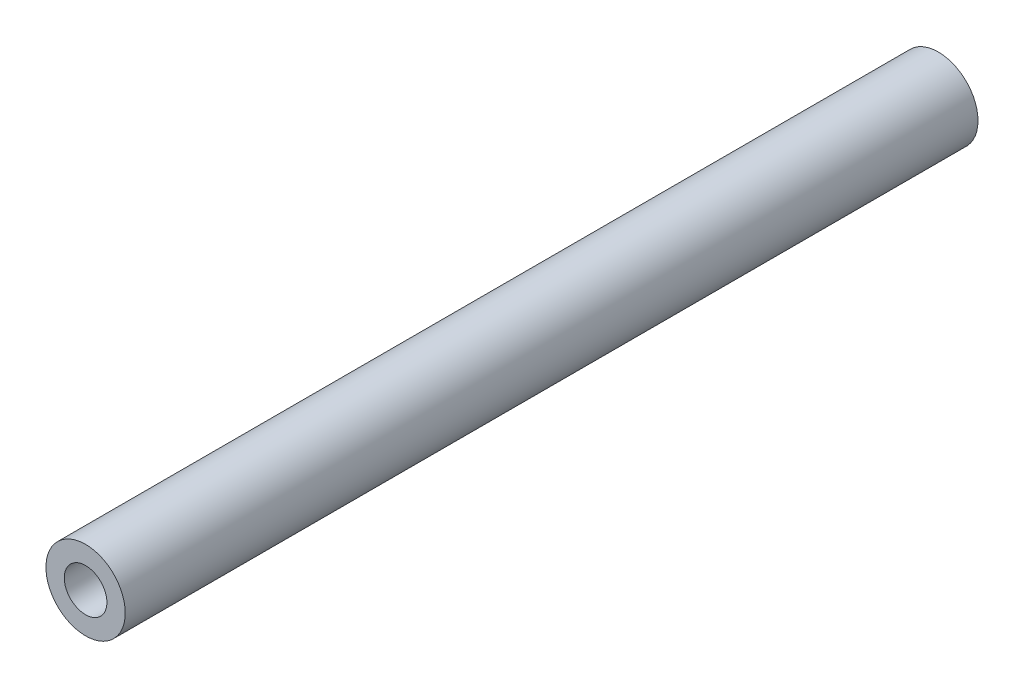
from build123d import *

# Parameters (mm, degrees)
SKETCH1_R           = 2.3622
SKETCH1_R_2         = 1.27
BOSS_EXTRUDE1_DEPTH = 50.8


with BuildPart() as part:
    # Sketch1 → Boss-Extrude1 (new body)
    with BuildSketch(Plane.XY):
        Circle(SKETCH1_R)
        Circle(SKETCH1_R_2, mode=Mode.SUBTRACT)
    extrude(amount=BOSS_EXTRUDE1_DEPTH)


solid = part.part
